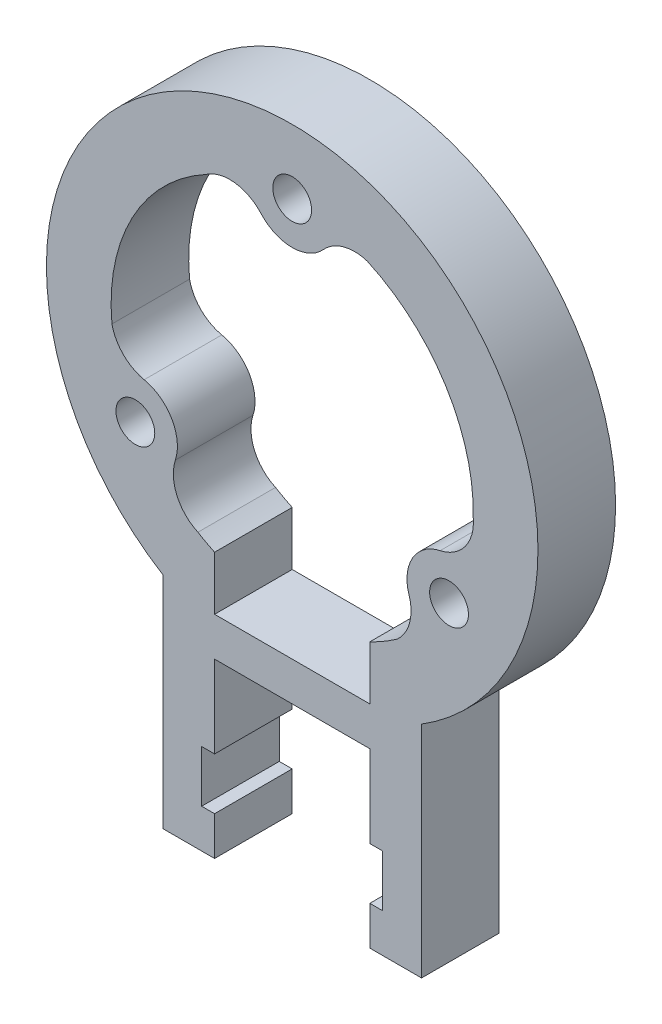
from build123d import *

# Parameters (mm, degrees)
ESQUISSE1_R        = 1.5
BOSS_EXTRU_2_DEPTH = 6


with BuildPart() as part:
    # Esquisse1 → Boss.-Extru.2 (new body)
    with BuildSketch(Plane.XY):
        with BuildLine():
            Line((-6, -33.155494421), (-6, -30.155494421))
            Line((-6, -30.155494421), (-7, -30.155494421))
            Line((-7, -30.155494421), (-7, -26.155494421))
            Line((-7, -26.155494421), (-6, -26.155494421))
            Line((-6, -26.155494421), (-6, -19.805494421))
            Line((-6, -19.805494421), (6, -19.805494421))
            Line((6, -19.805494421), (6, -26.155494421))
            Line((6, -26.155494421), (7, -26.155494421))
            Line((7, -26.155494421), (7, -30.155494421))
            Line((7, -30.155494421), (6, -30.155494421))
            Line((6, -30.155494421), (6, -33.155494421))
            Line((6, -33.155494421), (10, -33.155494421))
            Line((10, -33.155494421), (10, -16.155494421))
            ThreePointArc((10, -16.155494421), (0, 19), (-10, -16.155494421))
            Line((-10, -16.155494421), (-10, -33.155494421))
            Line((-10, -33.155494421), (-6, -33.155494421))
        make_face()
        with Locations((0, 14)):
            Circle(ESQUISSE1_R, mode=Mode.SUBTRACT)
        with Locations((12.124355653, -7)):
            Circle(ESQUISSE1_R, mode=Mode.SUBTRACT)
        with Locations((-12.124355653, -7)):
            Circle(ESQUISSE1_R, mode=Mode.SUBTRACT)
        with BuildLine():
            Line((6, -16.805494421), (-6, -16.805494421))
            Line((-6, -16.805494421), (-6, -12.649110641))
            ThreePointArc((-6, -12.649110641), (-6.653410863, -12.317959405), (-7.288606081, -11.953084179))
            ThreePointArc((-7.288606081, -11.953084179), (-8.912631465, -10.307392628), (-9.031496673, -7.998360322))
            ThreePointArc((-9.031496673, -7.998360322), (-9.309773091, -5.375), (-11.442531564, -3.822325392))
            ThreePointArc((-11.442531564, -3.822325392), (-13.054716827, -2.946828253), (-13.935938611, -1.337764944))
            ThreePointArc((-13.935938611, -1.337764944), (-12.367555464, 6.560760004), (-6.707371512, 12.288660114))
            ThreePointArc((-6.707371512, 12.288660114), (-4.47014813, 12.872261577), (-2.411034891, 11.820685714))
            ThreePointArc((-2.411034891, 11.820685714), (0, 10.75), (2.411034891, 11.820685714))
            ThreePointArc((2.411034891, 11.820685714), (3.975330286, 12.779130538), (5.80943088, 12.737759334))
            ThreePointArc((5.80943088, 12.737759334), (11.865562564, 7.430237213), (13.995977593, -0.335575935))
            ThreePointArc((13.995977593, -0.335575935), (13.382779595, -2.564868949), (11.442531564, -3.822325392))
            ThreePointArc((11.442531564, -3.822325392), (9.309773091, -5.375), (9.031496673, -7.998360322))
            ThreePointArc((9.031496673, -7.998360322), (9.079386541, -9.832302285), (8.126507731, -11.399994391))
            ThreePointArc((8.126507731, -11.399994391), (7.090812931, -12.071469338), (6, -12.649110641))
            Line((6, -12.649110641), (6, -16.805494421))
        make_face(mode=Mode.SUBTRACT)
    extrude(amount=BOSS_EXTRU_2_DEPTH)


solid = part.part
